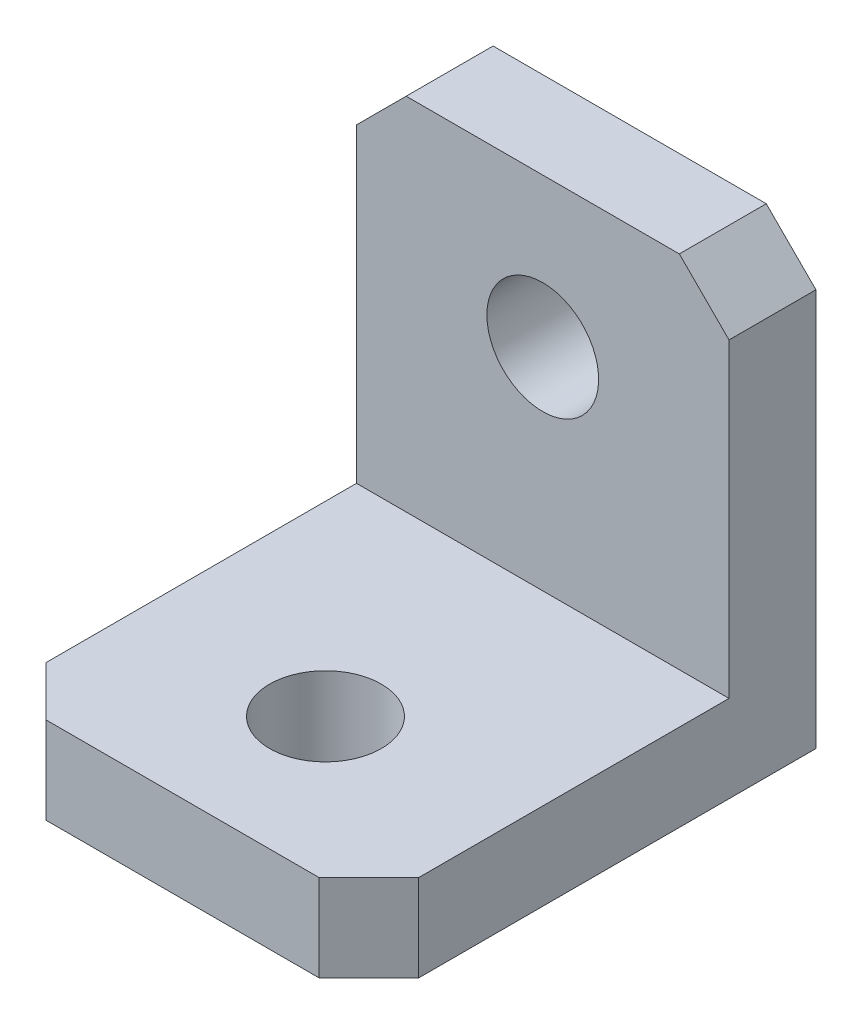
from build123d import *

# Parameters (mm, degrees)
SALIENTE_EXTRUIR1_DEPTH = 7.5
CROQUIS2_R              = 2.25
CORTAR_EXTRUIR1_DEPTH   = 15
CROQUIS3_R              = 2.25
CORTAR_EXTRUIR2_DEPTH   = 15
CHAFL_N1_SIZE           = 2


with BuildPart() as part:
    # Croquis1 → Saliente-Extruir1 (new body, symmetric)
    with BuildSketch(Plane(origin=(0, 0, 0), x_dir=(0, 0, -1), z_dir=(1, 0, 0))):
        Polygon((0, 0), (0, 3.5), (14.5, 3.5), (14.5, 18), (18, 18), (18, 0), align=None)
    extrude(amount=SALIENTE_EXTRUIR1_DEPTH, both=True)

    # Croquis2 → Cortar-Extruir1 (cut)
    with BuildSketch(Plane.XZ):
        with Locations((0, -5.75)):
            Circle(CROQUIS2_R)
    extrude(amount=-CORTAR_EXTRUIR1_DEPTH, mode=Mode.SUBTRACT)

    # Croquis3 → Cortar-Extruir2 (cut)
    with BuildSketch(Plane(origin=(0, 0, -18), x_dir=(-1, 0, 0), z_dir=(0, 0, -1))):
        with Locations((0, 12)):
            Circle(CROQUIS3_R)
    extrude(amount=-CORTAR_EXTRUIR2_DEPTH, mode=Mode.SUBTRACT)

    # Chaflán1
    chafl_n1_edges = [part.edges().sort_by_distance(p)[0] for p in [
        (7.5, 18, -16.25),
        (7.5, 1.75, 0),
        (-7.5, 1.75, 0),
        (-7.5, 18, -16.25),
    ]]
    chamfer(chafl_n1_edges, length=CHAFL_N1_SIZE)


solid = part.part
